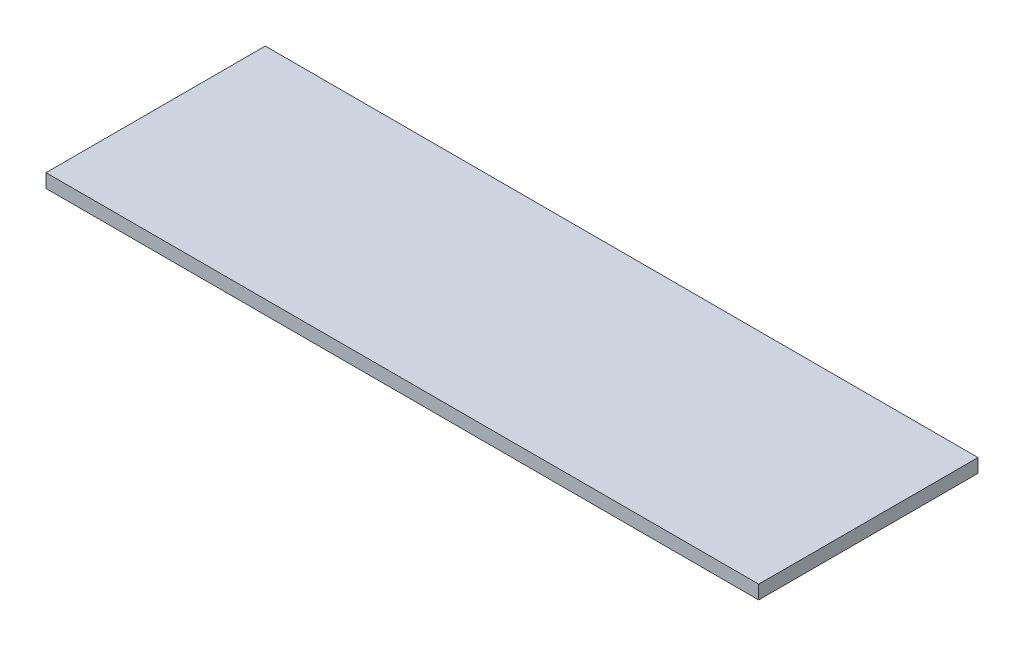
from build123d import *

# Parameters (mm, degrees)
SKETCH1_W           = 330.2
SKETCH1_H           = 101.6
BOSS_EXTRUDE1_DEPTH = 6.35


with BuildPart() as part:
    # Sketch1 → Boss-Extrude1 (new body)
    with BuildSketch(Plane(origin=(0, 0, 0), x_dir=(1, 0, 0), z_dir=(0, 1, 0))):
        Rectangle(SKETCH1_W, SKETCH1_H)
    extrude(amount=BOSS_EXTRUDE1_DEPTH)


solid = part.part
